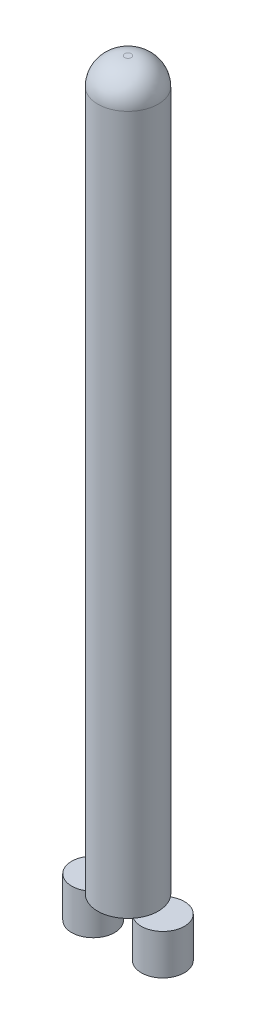
from build123d import *

# Parameters (mm, degrees)
SKETCH1_R             = 45
SKETCH1_R_2           = 42
BOSS_EXTRUDE1_DEPTH   = 1000
SKETCH2_R             = 45
BOSS_EXTRUDE2_DEPTH   = 80
FILLET1_R             = 40
SKETCH3_R             = 32
BOSS_EXTRUDE3_DEPTH   = 60
BOSS_EXTRUDE3_2_DEPTH = 60


with BuildPart() as part:
    # Sketch1 → Boss-Extrude1 (new body)
    with BuildSketch(Plane(origin=(0, 0, 0), x_dir=(1, 0, 0), z_dir=(0, 1, 0))):
        Circle(SKETCH1_R)
        Circle(SKETCH1_R_2, mode=Mode.SUBTRACT)
    extrude(amount=BOSS_EXTRUDE1_DEPTH)

    # Sketch2 → Boss-Extrude2 (add)
    with BuildSketch(Plane(origin=(0, 1000, 0), x_dir=(1, 0, 0), z_dir=(0, 1, 0))):
        Circle(SKETCH2_R)
    extrude(amount=BOSS_EXTRUDE2_DEPTH)

    # Fillet1
    fillet1_edges = [part.edges().sort_by_distance(p)[0] for p in [
        (-45, 1080, 0),
    ]]
    fillet(fillet1_edges, radius=FILLET1_R)


with BuildPart() as body_2:
    # Sketch3 → Boss-Extrude3 (new body)
    with BuildSketch(Plane(origin=(0, 0, 0), x_dir=(1, 0, 0), z_dir=(0, 1, 0))):
        with Locations((51.85084031, 0)):
            Circle(SKETCH3_R)
    extrude(amount=-BOSS_EXTRUDE3_DEPTH)


with BuildPart() as body_3:
    # Sketch3 → Boss-Extrude3 2 (new body)
    with BuildSketch(Plane(origin=(0, 0, 0), x_dir=(1, 0, 0), z_dir=(0, 1, 0))):
        with Locations((-51.85084031, 0)):
            Circle(SKETCH3_R)
    extrude(amount=-BOSS_EXTRUDE3_2_DEPTH)


solid = Compound([part.part, body_2.part, body_3.part])
